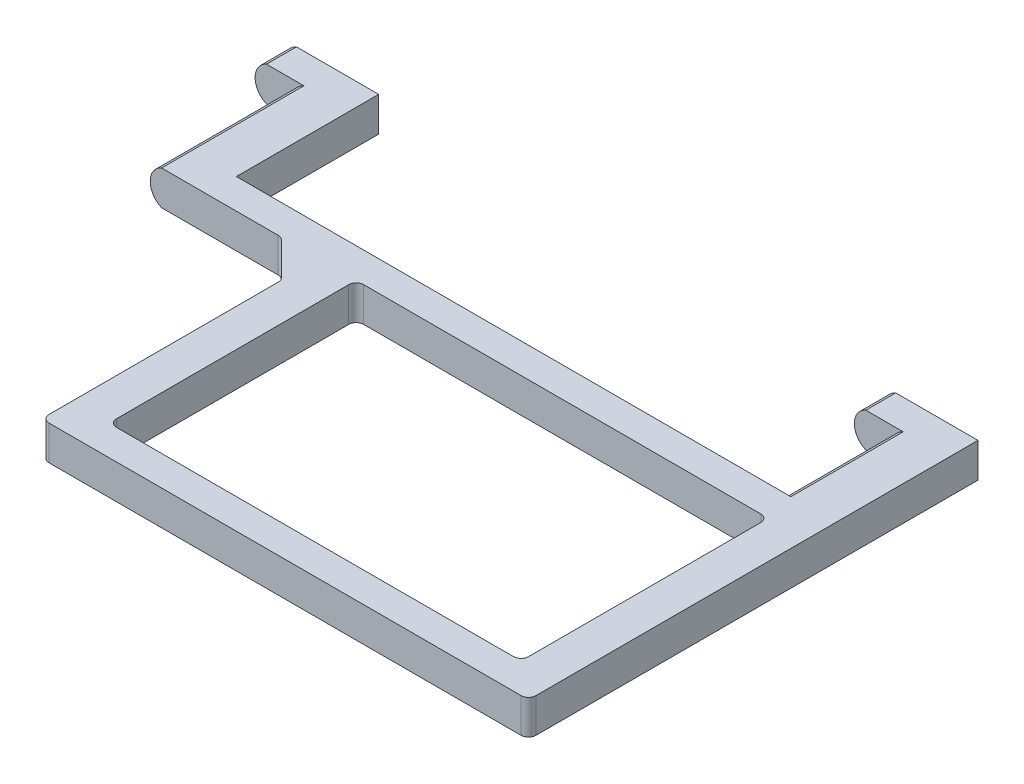
from build123d import *

# Parameters (mm, degrees)
EXTRUDE_1_DEPTH     = 15
EXTRUDE_1_2_DEPTH   = 15
EXTRUDE_2_DEPTH     = 4
EXTRUDE_5_DEPTH     = 4
SKETCH_8_W          = 5
SKETCH_8_H          = 5
EXTRUDE_6_DEPTH     = 37
SKETCH_9_W          = 4
SKETCH_9_H          = 5
EXTRUDE_7_DEPTH     = 60
EXTRUDE_8_DEPTH     = 5
FILLET_1_R          = 1
FILLET_2_R          = 1
SKETCH_11_W         = 94.407997399
SKETCH_11_H         = 0.2
CUT_EXTRUDE_1_DEPTH = 61


with BuildPart() as part:
    # 草图1 → 凸台-拉伸1 (new body)
    with BuildSketch(Plane.XY):
        with BuildLine():
            Line((539.301234579, 452.744075086), (539.301234579, 447.744075086))
            Line((539.301234579, 447.744075086), (534.301234579, 447.744075086))
            ThreePointArc((534.301234579, 447.744075086), (531.801234579, 450.244075086), (534.301234579, 452.744075086))
            Line((534.301234579, 452.744075086), (539.301234579, 452.744075086))
        make_face()
    extrude(amount=-EXTRUDE_1_DEPTH)



with BuildPart() as body_2:
    # 草图1 → Extrude 1 2 (new body)
    with BuildSketch(Plane.XY):
        with BuildLine():
            Line((459.301234579, 452.744075086), (459.301234579, 447.744075086))
            Line((459.301234579, 447.744075086), (454.301234579, 447.744075086))
            ThreePointArc((454.301234579, 447.744075086), (451.801234579, 450.244075086), (454.301234579, 452.744075086))
            Line((454.301234579, 452.744075086), (459.301234579, 452.744075086))
        make_face()
    extrude(amount=-EXTRUDE_1_2_DEPTH)


with BuildPart() as part_1:
    add(part.part)

    add(body_2.part)  # 凸台-拉伸2 merges body 2
    # 草图2 → 凸台-拉伸2 (add)
    with BuildSketch(Plane(origin=(0, 0, -15), x_dir=(-1, 0, 0), z_dir=(0, 0, -1))):
        with BuildLine():
            Line((-529.301234579, 452.744075086), (-534.301234579, 452.744075086))
            Line((-534.301234579, 452.744075086), (-539.301234579, 452.744075086))
            Line((-539.301234579, 452.744075086), (-539.301234579, 447.744075086))
            Line((-539.301234579, 447.744075086), (-534.301234579, 447.744075086))
            Line((-534.301234579, 447.744075086), (-529.301234579, 447.744075086))
            ThreePointArc((-529.301234579, 447.744075086), (-526.801234579, 450.244075086), (-529.301234579, 452.744075086))
        make_face()
        with BuildLine():
            Line((-449.301234579, 452.744075086), (-459.301234579, 452.744075086))
            Line((-459.301234579, 452.744075086), (-459.301234579, 447.744075086))
            Line((-459.301234579, 447.744075086), (-449.301234579, 447.744075086))
            ThreePointArc((-449.301234579, 447.744075086), (-446.801234579, 450.244075086), (-449.301234579, 452.744075086))
        make_face()
    extrude(amount=EXTRUDE_2_DEPTH)

    # 草图7 → 凸台-拉伸5 (add)
    with BuildSketch(Plane.XY):
        with BuildLine():
            Line((539.301234579, 447.744075086), (454.301234579, 447.744075086))
            ThreePointArc((454.301234579, 447.744075086), (451.801234579, 450.244075086), (454.301234579, 452.744075086))
            Line((454.301234579, 452.744075086), (539.301234579, 452.744075086))
            Line((539.301234579, 452.744075086), (539.301234579, 447.744075086))
        make_face()
    extrude(amount=EXTRUDE_5_DEPTH)

    # 草图8 → 凸台-拉伸6 (add)
    with BuildSketch(Plane.XY.offset(4)):
        with Locations((536.801234579, 450.244075086)):
            Rectangle(SKETCH_8_W, SKETCH_8_H)
        with Locations((476.801234579, 450.244075086)):
            Rectangle(SKETCH_8_W, SKETCH_8_H)
    extrude(amount=EXTRUDE_6_DEPTH)

    # 草图9 → 凸台-拉伸7 (add)
    with BuildSketch(Plane.ZY.offset(-534.301234579)):
        with Locations((39, 450.244075086)):
            Rectangle(SKETCH_9_W, SKETCH_9_H)
    extrude(amount=EXTRUDE_7_DEPTH)

    # 草图10 → 凸台-拉伸8 (add)
    with BuildSketch(Plane.XZ.offset(-447.744075086)):
        Polygon((474.301234579, 4), (469.301234579, 4), (474.301234579, 9), align=None)
    extrude(amount=-EXTRUDE_8_DEPTH)

    # 圆角1
    fillet_1_edges = [part_1.edges().sort_by_distance(p)[0] for p in [
        (534.301234579, 450.244075086, 4),
        (479.301234579, 450.244075086, 4),
        (479.301234579, 450.244075086, 37),
        (534.301234579, 450.244075086, 37),
    ]]
    fillet(fillet_1_edges, radius=FILLET_1_R)

    # 圆角2
    fillet_2_edges = [part_1.edges().sort_by_distance(p)[0] for p in [
        (469.301234579, 450.244075086, 4),
        (474.301234579, 450.244075086, 9),
        (539.301234579, 450.244075086, 41),
        (474.301234579, 450.244075086, 41),
    ]]
    fillet(fillet_2_edges, radius=FILLET_2_R)

    # 草图11 → 切除-拉伸1 (cut, through all)
    with BuildSketch(Plane.XY.offset(41)):
        with Locations((493.383672974, 452.644075086)):
            Rectangle(SKETCH_11_W, SKETCH_11_H)
        with Locations((493.383672974, 447.844075086)):
            Rectangle(SKETCH_11_W, SKETCH_11_H)
    extrude(amount=-CUT_EXTRUDE_1_DEPTH, mode=Mode.SUBTRACT)


solid = part_1.part
